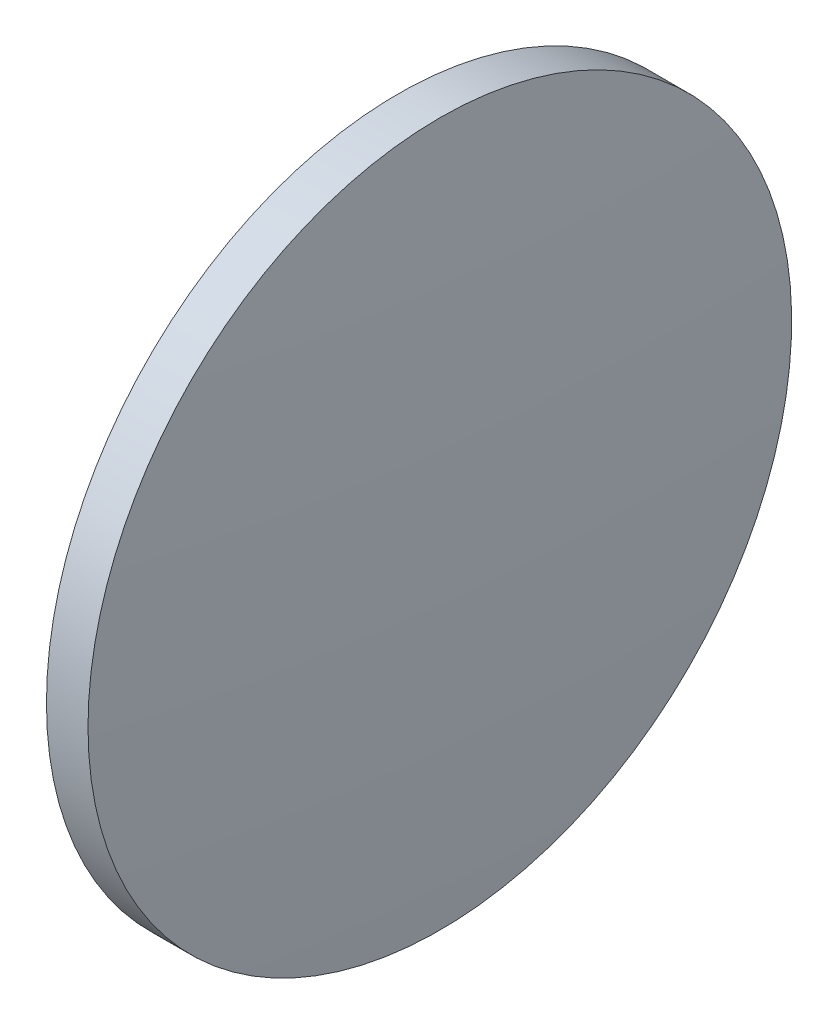
from build123d import *


with BuildPart() as part:
    # 草图1 → 旋转1 (revolve)
    with BuildSketch(Plane.XY):
        with BuildLine():
            Line((232.020820079, 130.467109853), (232.020820079, 155.867109853))
            Line((232.020820079, 155.867109853), (235.020820079, 155.867109853))
            ThreePointArc((235.020820079, 155.867109853), (235.695749502, 143.175079793), (235.920820079, 130.467109853))
            Line((235.920820079, 130.467109853), (232.020820079, 130.467109853))
        make_face()
    revolve(axis=Axis((220.330746457, 130.467109853, 0), (1, 0, 0)))


solid = part.part
